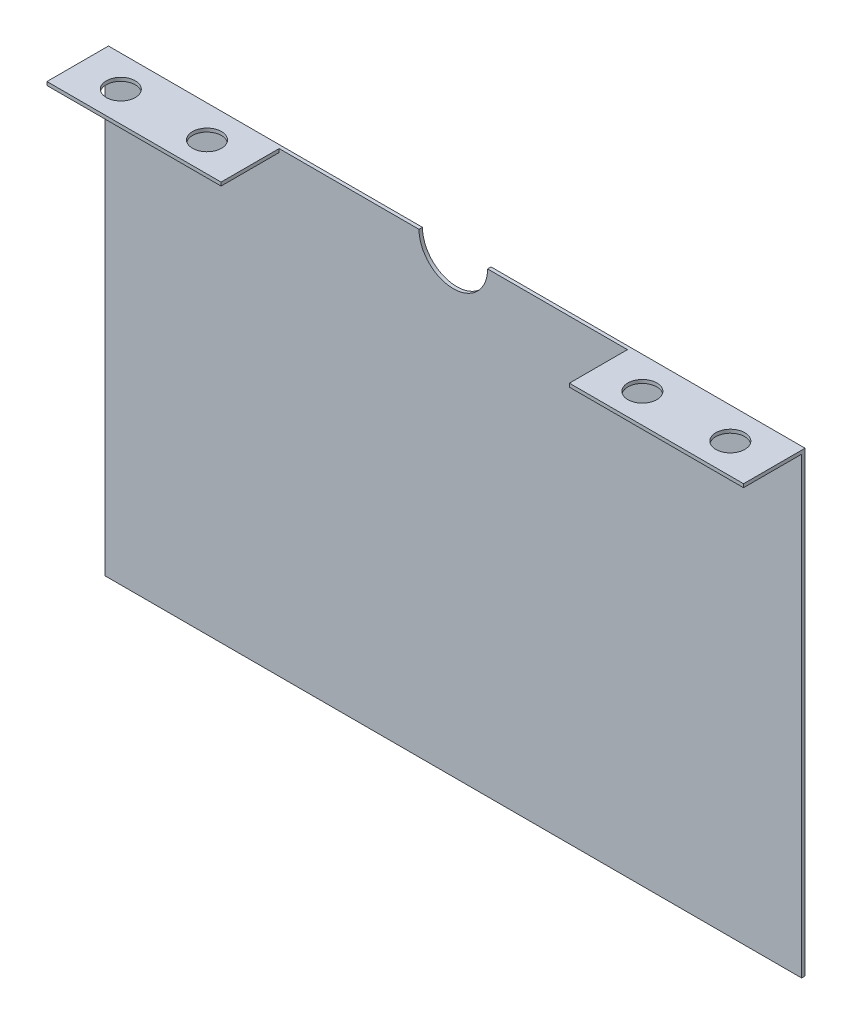
from build123d import *

# Parameters (mm, degrees)
BOTTOM_CENTER_CASING_DEPTH = 1.51892
SKETCH3_W                  = 76.2
SKETCH3_H                  = 1.51892
BOSS_EXTRUDE1_DEPTH        = 25.4
SKETCH4_R                  = 6.35
CUT_EXTRUDE1_DEPTH         = 25.4


with BuildPart() as part:
    # Sketch1 → Bottom Center Casing (new body)
    with BuildSketch(Plane.XY):
        with BuildLine():
            Line((-152.4, 100), (-15, 100))
            ThreePointArc((-15, 100), (0, 85), (15, 100))
            Line((15, 100), (152.4, 100))
            Line((152.4, 100), (152.4, -100))
            Line((152.4, -100), (-152.4, -100))
            Line((-152.4, -100), (-152.4, 100))
        make_face()
    extrude(amount=BOTTOM_CENTER_CASING_DEPTH)

    # Sketch3 → Boss-Extrude1 (add)
    with BuildSketch(Plane.XY.offset(1.51892)):
        with Locations((-114.3, 99.24054)):
            Rectangle(SKETCH3_W, SKETCH3_H)
        with Locations((114.3, 99.24054)):
            Rectangle(SKETCH3_W, SKETCH3_H)
    extrude(amount=BOSS_EXTRUDE1_DEPTH)

    # Sketch4 → Cut-Extrude1 (cut)
    with BuildSketch(Plane(origin=(0, 100, 0), x_dir=(1, 0, 0), z_dir=(0, 1, 0))):
        with Locations((-133.35, -13.649325)):
            Circle(SKETCH4_R)
        with Locations((-95.25, -14.029055)):
            Circle(SKETCH4_R)
        with Locations((95.25, -14.029055)):
            Circle(SKETCH4_R)
        with Locations((133.35, -13.649325)):
            Circle(SKETCH4_R)
    extrude(amount=-CUT_EXTRUDE1_DEPTH, mode=Mode.SUBTRACT)


solid = part.part
